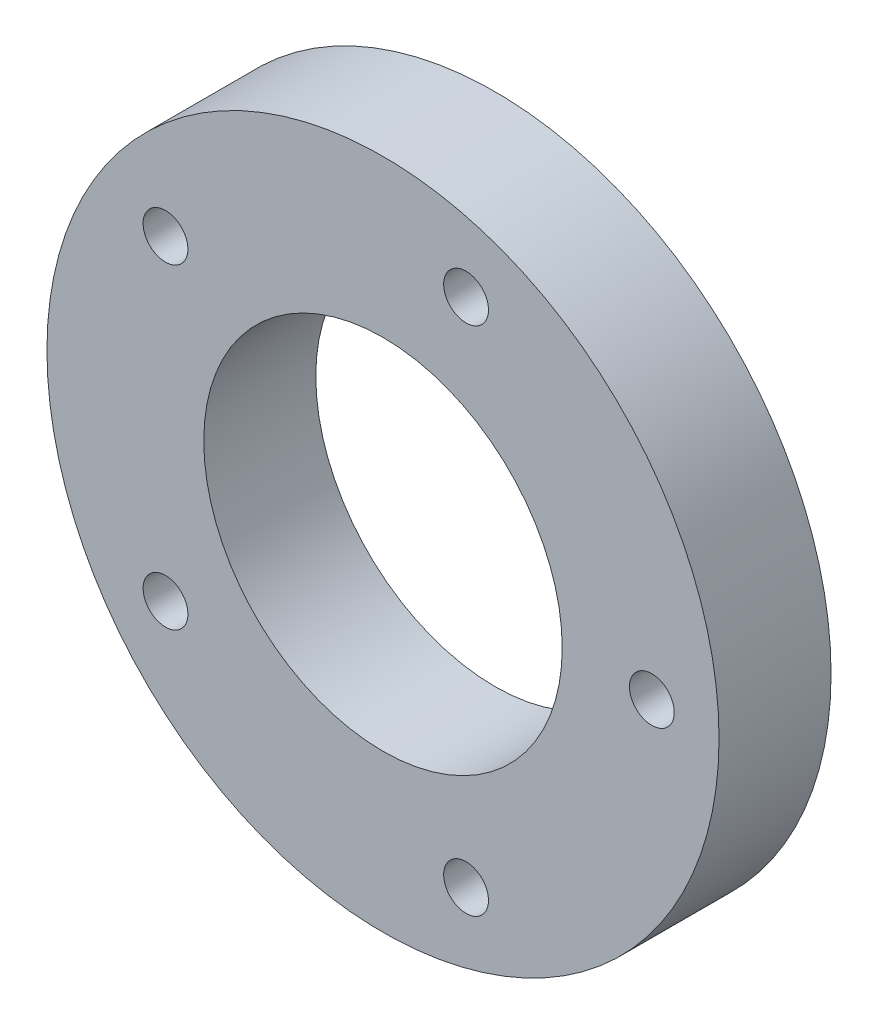
from build123d import *

# Parameters (mm, degrees)
SKETCH1_R           = 30
SKETCH1_R_2         = 16
SKETCH1_R_3         = 2
BOSS_EXTRUDE1_DEPTH = 10


with BuildPart() as part:
    # Sketch1 → Boss-Extrude1 (new body)
    with BuildSketch(Plane.XY):
        Circle(SKETCH1_R)
        Circle(SKETCH1_R_2, mode=Mode.SUBTRACT)
        with Locations((24, 0)):
            Circle(SKETCH1_R_3, mode=Mode.SUBTRACT)
        with Locations((7.416407865, -22.825356391)):
            Circle(SKETCH1_R_3, mode=Mode.SUBTRACT)
        with Locations((-19.416407865, -14.106846055)):
            Circle(SKETCH1_R_3, mode=Mode.SUBTRACT)
        with Locations((-19.416407865, 14.106846055)):
            Circle(SKETCH1_R_3, mode=Mode.SUBTRACT)
        with Locations((7.416407865, 22.825356391)):
            Circle(SKETCH1_R_3, mode=Mode.SUBTRACT)
    extrude(amount=-BOSS_EXTRUDE1_DEPTH)


solid = part.part
